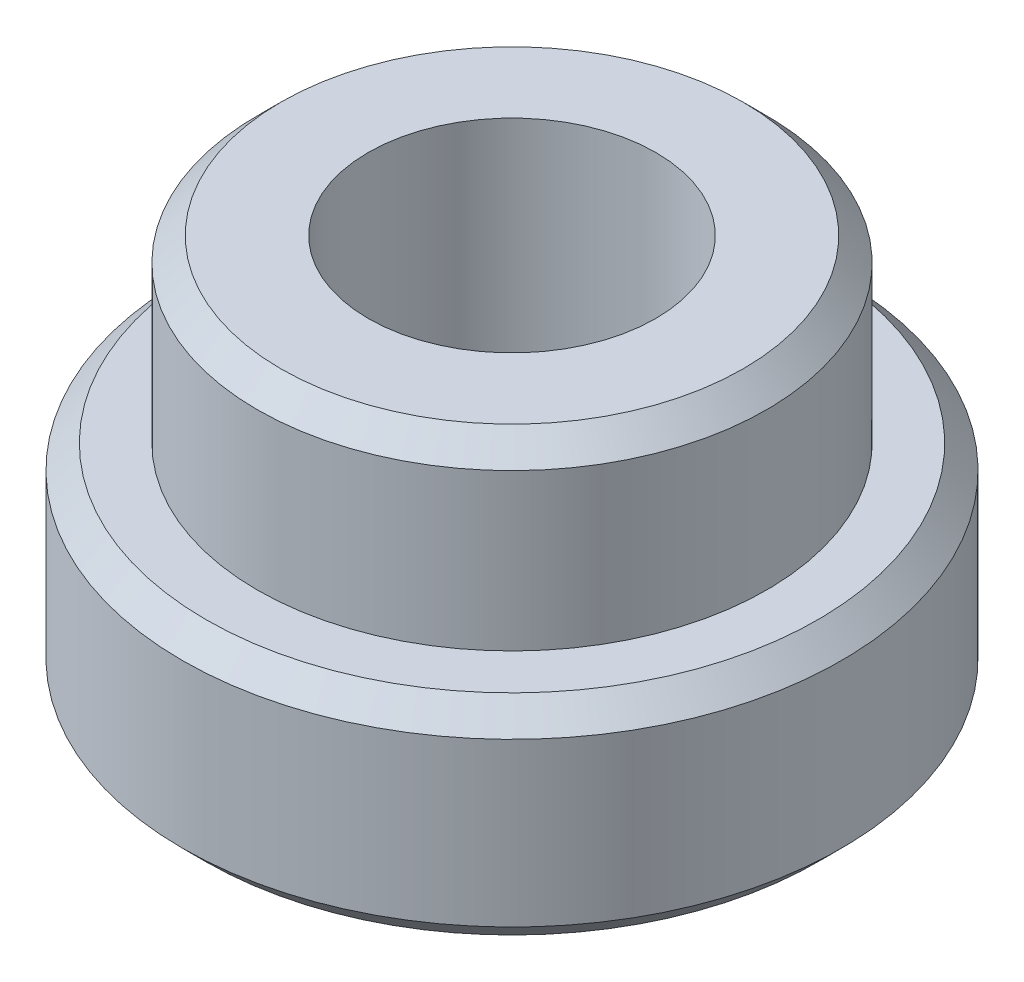
from build123d import *

# Parameters (mm, degrees)
SKETCH1_R           = 2.794
BOSS_EXTRUDE1_DEPTH = 1.778
CHAMFER1_SIZE       = 0.2
SKETCH2_R           = 2.159
BOSS_EXTRUDE2_DEPTH = 1.524
CHAMFER2_SIZE       = 0.2
SKETCH3_R           = 1.2192
CUT_EXTRUDE1_DEPTH  = 4.302


with BuildPart() as part:
    # Sketch1 → Boss-Extrude1 (new body)
    with BuildSketch(Plane(origin=(0, 0, 0), x_dir=(1, 0, 0), z_dir=(0, 1, 0))):
        Circle(SKETCH1_R)
    extrude(amount=BOSS_EXTRUDE1_DEPTH)

    # Chamfer1
    chamfer1_edges = [part.edges().sort_by_distance(p)[0] for p in [
        (-2.794, 0, 0),
        (-2.794, 1.778, 0),
    ]]
    chamfer(chamfer1_edges, length=CHAMFER1_SIZE)

    # Sketch2 → Boss-Extrude2 (add)
    with BuildSketch(Plane(origin=(0, 1.778, 0), x_dir=(1, 0, 0), z_dir=(0, 1, 0))):
        Circle(SKETCH2_R)
    extrude(amount=BOSS_EXTRUDE2_DEPTH)

    # Chamfer2
    chamfer2_edges = [part.edges().sort_by_distance(p)[0] for p in [
        (-2.159, 3.302, 0),
    ]]
    chamfer(chamfer2_edges, length=CHAMFER2_SIZE)

    # Sketch3 → Cut-Extrude1 (cut, through all)
    with BuildSketch(Plane(origin=(0, 3.302, 0), x_dir=(1, 0, 0), z_dir=(0, 1, 0))):
        Circle(SKETCH3_R)
    extrude(amount=-CUT_EXTRUDE1_DEPTH, mode=Mode.SUBTRACT)


solid = part.part
